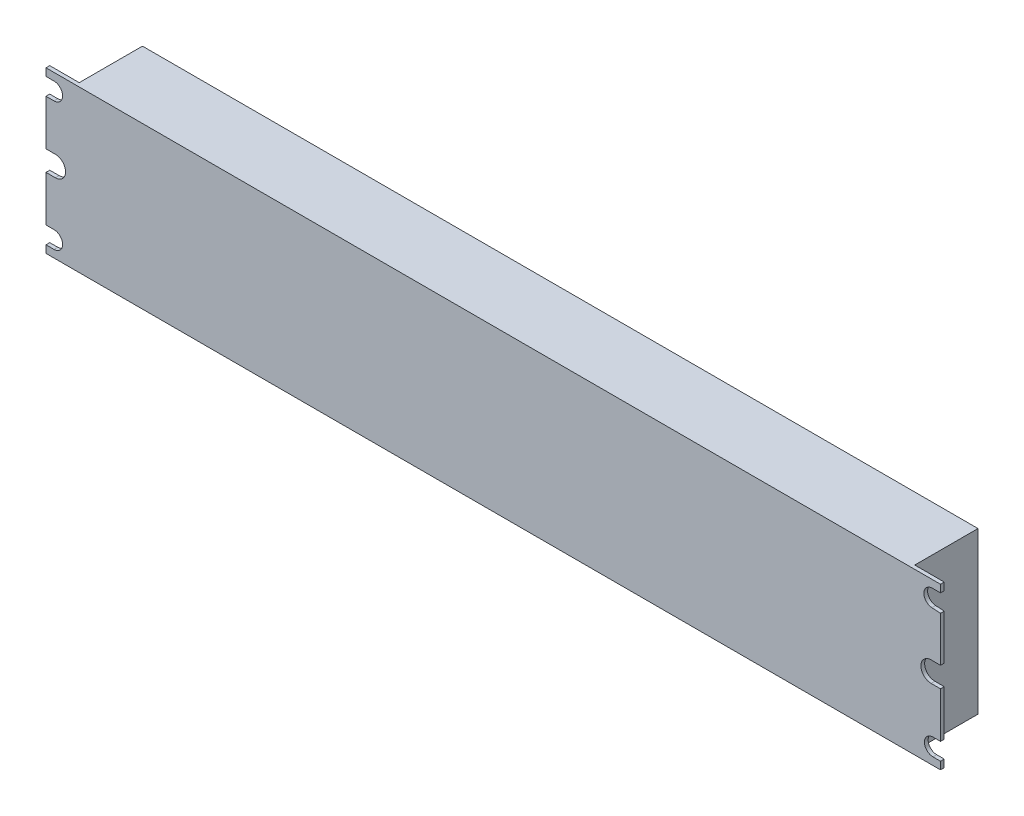
from build123d import *

# Parameters (mm, degrees)
SKETCH1_W           = 423.926
SKETCH1_H           = 31.75
BOSS_EXTRUDE1_DEPTH = 76.2
SKETCH5_W           = 13.97
SKETCH5_H           = 76.2
CUT_EXTRUDE5_DEPTH  = 29.972
SKETCH6_R           = 4.064
SKETCH6_R_2         = 4.826
CUT_EXTRUDE6_DEPTH  = 416.56
CUT_EXTRUDE7_DEPTH  = 2.778


with BuildPart() as part:
    # Sketch1 → Boss-Extrude1 (new body)
    with BuildSketch(Plane(origin=(0, 0, 0), x_dir=(1, 0, 0), z_dir=(0, 1, 0))):
        with Locations((211.963, 15.875)):
            Rectangle(SKETCH1_W, SKETCH1_H)
    extrude(amount=BOSS_EXTRUDE1_DEPTH)

    # Sketch5 → Cut-Extrude5 (cut)
    with BuildSketch(Plane(origin=(0, 0, -31.75), x_dir=(-1, 0, 0), z_dir=(0, 0, -1))):
        with Locations((-416.941, 38.1)):
            Rectangle(SKETCH5_W, SKETCH5_H)
        with Locations((-6.985, 38.1)):
            Rectangle(SKETCH5_W, SKETCH5_H)
    extrude(amount=-CUT_EXTRUDE5_DEPTH, mode=Mode.SUBTRACT)

    # Sketch6 → Cut-Extrude6 (cut)
    with BuildSketch(Plane(origin=(0, 0, -1.778), x_dir=(-1, 0, 0), z_dir=(0, 0, -1))):
        with Locations((-3.81, 7.62)):
            Circle(SKETCH6_R)
        with Locations((-3.81, 68.58)):
            Circle(SKETCH6_R)
        with Locations((-4.445, 38.1)):
            Circle(SKETCH6_R_2)
        with Locations((-420.37, 7.62)):
            Circle(SKETCH6_R)
        with Locations((-420.116, 68.58)):
            Circle(SKETCH6_R)
        with Locations((-419.481, 38.1)):
            Circle(SKETCH6_R_2)
    extrude(amount=-CUT_EXTRUDE6_DEPTH, mode=Mode.SUBTRACT)

    # Sketch8 → Cut-Extrude7 (cut, through all)
    with BuildSketch(Plane(origin=(0, 0, -1.778), x_dir=(-1, 0, 0), z_dir=(0, 0, -1))):
        Polygon((-419.862, 72.636054733), (-423.926, 72.636054733), (-423.926, 69.994212148), align=None)
        Polygon((-419.862, 64.523945267), (-423.926, 64.269447715), (-423.926, 67.165787852), align=None)
        Polygon((-419.481, 42.926), (-423.926, 42.926), (-423.926, 39.979428371), align=None)
        Polygon((-419.481, 33.274), (-423.926, 33.274), (-423.926, 36.220571629), align=None)
        Polygon((-420.37, 11.684), (-423.926, 11.684), (-423.926, 9.58747554), align=None)
        Polygon((-420.37, 3.556), (-423.926, 3.556), (-423.926, 5.65252446), align=None)
        Polygon((-3.81, 72.644), (0, 72.644), (0, 69.994212148), align=None)
        Polygon((-3.81, 64.516), (0, 64.516), (0, 67.165787852), align=None)
        Polygon((-4.445, 42.926), (0, 42.926), (0, 39.979428371), align=None)
        Polygon((-4.445, 33.274), (0, 33.274), (0, 36.220571629), align=None)
        Polygon((-3.81, 11.684), (0, 11.684), (0, 9.034212148), align=None)
        Polygon((-3.81, 3.556), (0, 3.556), (0, 6.205787852), align=None)
    extrude(amount=-CUT_EXTRUDE7_DEPTH, mode=Mode.SUBTRACT)


solid = part.part
